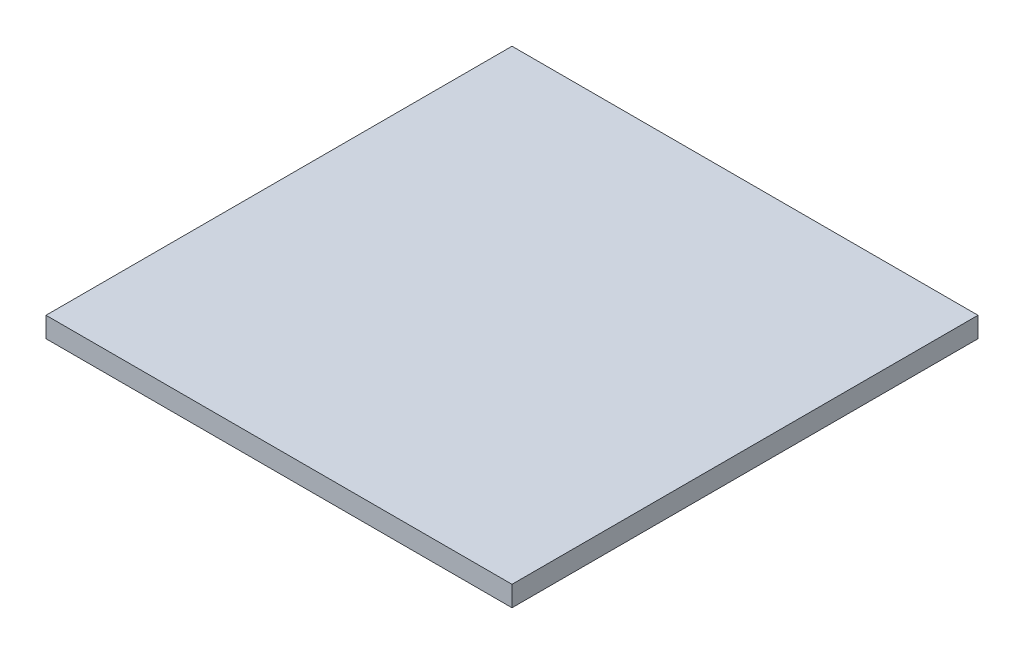
from build123d import *

# Parameters (mm, degrees)
SKETCH1_W           = 114.5
SKETCH1_H           = 114.5
BOSS_EXTRUDE1_DEPTH = 5


with BuildPart() as part:
    # Sketch1 → Boss-Extrude1 (new body)
    with BuildSketch(Plane(origin=(0, 0, 0), x_dir=(1, 0, 0), z_dir=(0, 1, 0))):
        Rectangle(SKETCH1_W, SKETCH1_H)
    extrude(amount=BOSS_EXTRUDE1_DEPTH)


solid = part.part
